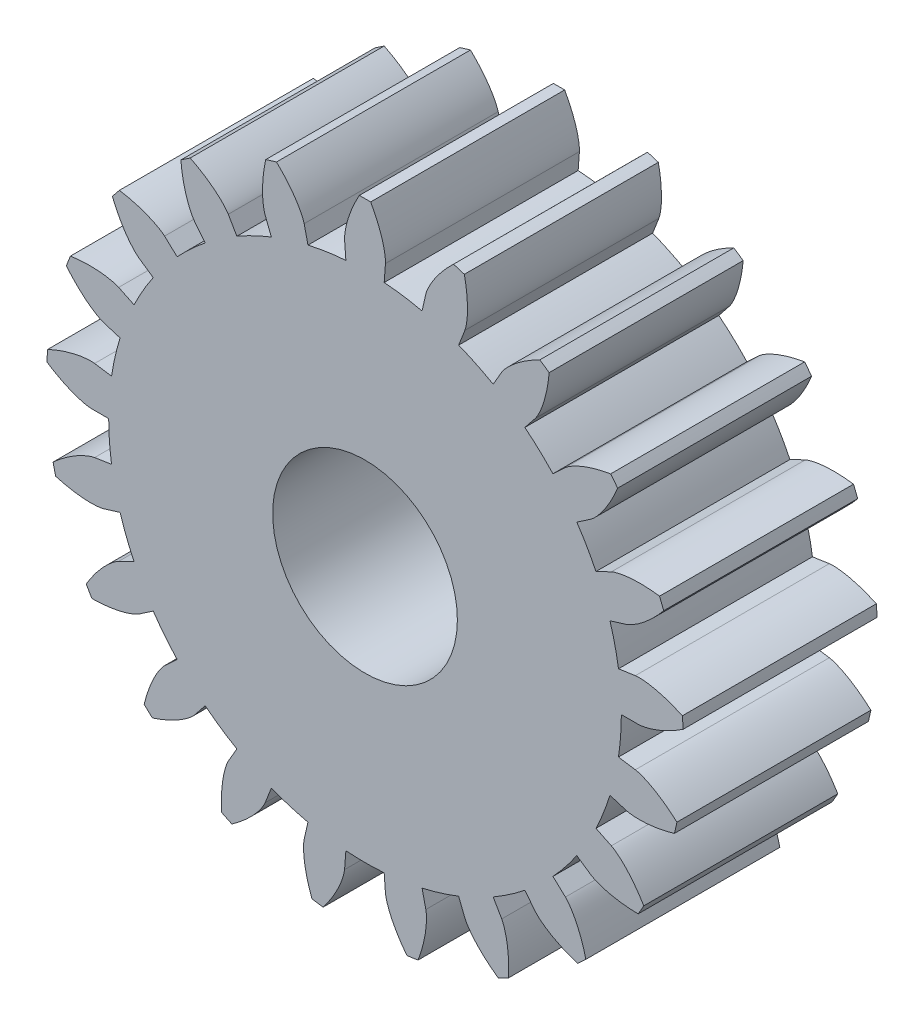
from build123d import *

# Parameters (mm, degrees)
SKICA1_R                = 10
P_IDAT_VYSUNUT_M1_DEPTH = 21
P_IDAT_VYSUNUT_M2_DEPTH = 21
KRUHOV_POLE1_COUNT      = 21


with BuildPart() as part:
    # Skica1 → P_idat vysunut_m1 (new body)
    with BuildSketch(Plane.XY):
        with BuildLine():
            ThreePointArc((27.75, 0), (20.342189443, 18.874793473), (2.073760097, 27.672405372))
            ThreePointArc((2.073760097, 27.672405372), (0, 27.75), (-2.073760097, 27.672405372))
            ThreePointArc((-2.073760097, 27.672405372), (-18.874793473, -20.342189443), (27.75, 0))
        make_face()
        Circle(SKICA1_R, mode=Mode.SUBTRACT)
    extrude(amount=P_IDAT_VYSUNUT_M1_DEPTH)

    # Skica1_3 → P_idat vysunut_m2 (add)
    with BuildSketch(Plane.XY):
        with BuildLine():
            Line((2.073760097, 27.672405372), (2.21201077, 29.517232397))
            add(Edge.make_bspline(
                [(2.21201077, 29.517232397), (2.212599542, 29.525089018), (2.213942073, 29.547148629), (2.215260227, 29.588942538), (2.215676546, 29.657238124), (2.21365643, 29.74437963), (2.208115185, 29.857108917), (2.197818491, 29.989989803), (2.18255424, 30.13605837), (2.161687718, 30.294959119), (2.137105038, 30.45342914), (2.109080449, 30.611417629), (2.078006178, 30.768688396), (2.036638111, 30.959019025), (1.98185462, 31.186972482), (1.91028945, 31.452904464), (1.820245342, 31.753820706), (1.719008921, 32.059609918), (1.611621352, 32.359718424), (1.49421916, 32.661879941), (1.374320651, 32.953477218), (1.240710098, 33.255093555), (1.112761807, 33.532869814), (0.959421624, 33.842511654), (0.837945226, 34.081725866), (0.708686558, 34.320396565), (0.642076835, 34.441191568), (0.612273543, 34.494566545)],
                knots=[0, 0, 0, 0, 0, 0.005376749, 0.015083688, 0.02853182, 0.04661014, 0.064854849, 0.092110526, 0.119476176, 0.146842496, 0.174208854, 0.201574956, 0.228941013, 0.256307345, 0.307035032, 0.361767352, 0.416499661, 0.471231937, 0.525964282, 0.580696616, 0.635428982, 0.690161387, 0.744893688, 0.799626082, 0.854358407, 0.900116248, 0.900116248, 0.900116248, 0.900116248, 0.900116248], degree=4))
            ThreePointArc((0.612273543, 34.494566545), (0, 34.5), (-0.612273543, 34.494566545))
            add(Edge.make_bspline(
                [(-2.21201077, 29.517232397), (-2.212599542, 29.525089018), (-2.213942073, 29.547148629), (-2.215260227, 29.588942538), (-2.215676546, 29.657238124), (-2.21365643, 29.74437963), (-2.208115185, 29.857108917), (-2.197818491, 29.989989803), (-2.18255424, 30.13605837), (-2.161687718, 30.294959119), (-2.137105038, 30.45342914), (-2.109080449, 30.611417629), (-2.078006178, 30.768688396), (-2.036638111, 30.959019025), (-1.98185462, 31.186972482), (-1.91028945, 31.452904464), (-1.820245342, 31.753820706), (-1.719008921, 32.059609918), (-1.611621352, 32.359718424), (-1.49421916, 32.661879941), (-1.374320651, 32.953477218), (-1.240710098, 33.255093555), (-1.112761807, 33.532869814), (-0.959421624, 33.842511654), (-0.837945226, 34.081725866), (-0.708686557, 34.320396565), (-0.642076835, 34.441191568), (-0.612273543, 34.494566545)],
                knots=[0, 0, 0, 0, 0, 0.005376749, 0.015083688, 0.02853182, 0.04661014, 0.064854849, 0.092110526, 0.119476176, 0.146842496, 0.174208854, 0.201574956, 0.228941013, 0.256307345, 0.307035032, 0.361767352, 0.416499661, 0.471231937, 0.525964282, 0.580696616, 0.635428982, 0.690161387, 0.744893688, 0.799626082, 0.854358407, 0.900116248, 0.900116248, 0.900116248, 0.900116248, 0.900116248], degree=4))
            Line((-2.21201077, 29.517232397), (-2.073760097, 27.672405372))
            ThreePointArc((-2.073760097, 27.672405372), (0, 27.75), (2.073760097, 27.672405372))
        make_face()
    p_idat_vysunut_m2 = extrude(amount=P_IDAT_VYSUNUT_M2_DEPTH)

    # Kruhov_ pole1: P_idat vysunut_m2 ×21 about axis
    kruhov_pole1_axis = Axis((0, 0, 21), (0, 0, 1))
    for i in range(1, KRUHOV_POLE1_COUNT):
        add(p_idat_vysunut_m2.rotate(kruhov_pole1_axis, i * 360 / KRUHOV_POLE1_COUNT))


solid = part.part
